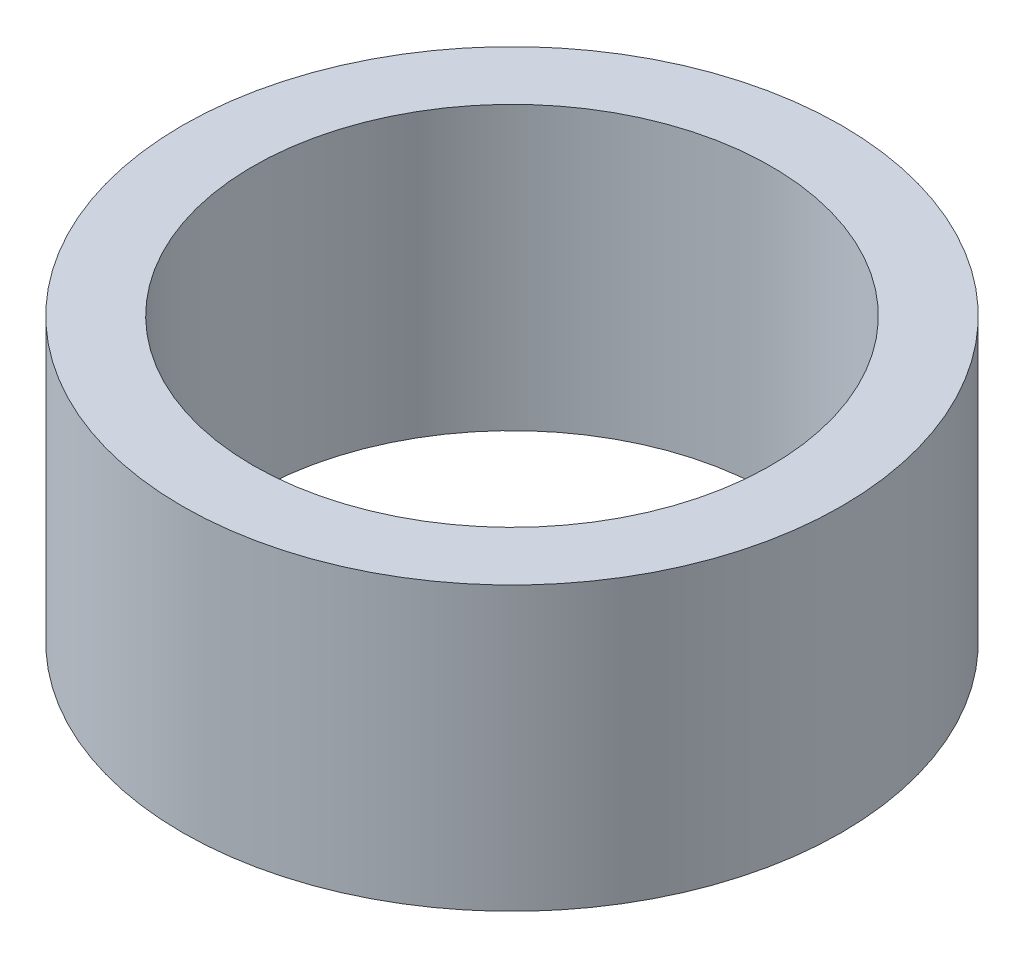
from build123d import *

# Parameters (mm, degrees)
SKETCH2_R           = 14
SKETCH2_R_2         = 11
BOSS_EXTRUDE1_DEPTH = 12


with BuildPart() as part:
    # Sketch2 → Boss-Extrude1 (new body)
    with BuildSketch(Plane(origin=(0, 0, 0), x_dir=(1, 0, 0), z_dir=(0, 1, 0))):
        Circle(SKETCH2_R)
        Circle(SKETCH2_R_2, mode=Mode.SUBTRACT)
    extrude(amount=BOSS_EXTRUDE1_DEPTH)


solid = part.part
